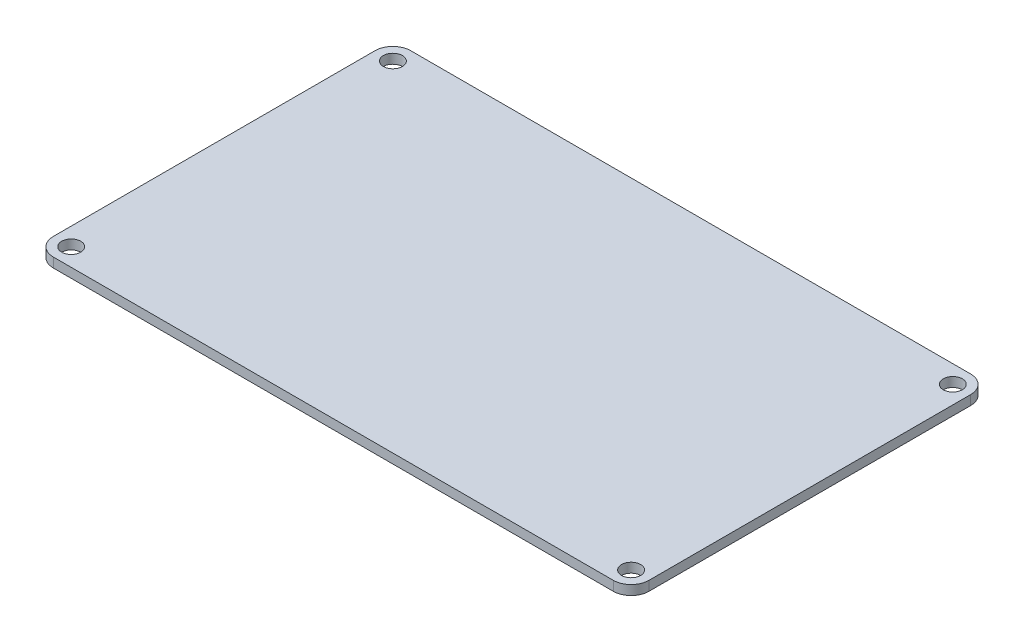
from build123d import *

# Parameters (mm, degrees)
SKETCH_1_W          = 100
SKETCH_1_H          = 60
EXTRUDE_1_DEPTH     = 1.6
SKETCH_2_R          = 1.6
CUT_EXTRUDE_1_DEPTH = 2.6
FILLET_1_R          = 3


with BuildPart() as part:
    # 草图1 → 凸台-拉伸1 (new body)
    with BuildSketch(Plane(origin=(0, 0, 0), x_dir=(1, 0, 0), z_dir=(0, 1, 0))):
        Rectangle(SKETCH_1_W, SKETCH_1_H)
    extrude(amount=EXTRUDE_1_DEPTH)

    # 草图2 → 切除-拉伸1 (cut, through all)
    with BuildSketch(Plane(origin=(0, 1.6, 0), x_dir=(1, 0, 0), z_dir=(0, 1, 0))):
        with Locations((-47, 27)):
            Circle(SKETCH_2_R)
        with Locations((47, 27)):
            Circle(SKETCH_2_R)
        with Locations((47, -27)):
            Circle(SKETCH_2_R)
        with Locations((-47, -27)):
            Circle(SKETCH_2_R)
    extrude(amount=-CUT_EXTRUDE_1_DEPTH, mode=Mode.SUBTRACT)

    # 圆角1
    fillet_1_edges = [part.edges().sort_by_distance(p)[0] for p in [
        (-50, 0.8, 30),
        (-50, 0.8, -30),
        (50, 0.8, -30),
        (50, 0.8, 30),
    ]]
    fillet(fillet_1_edges, radius=FILLET_1_R)


solid = part.part
